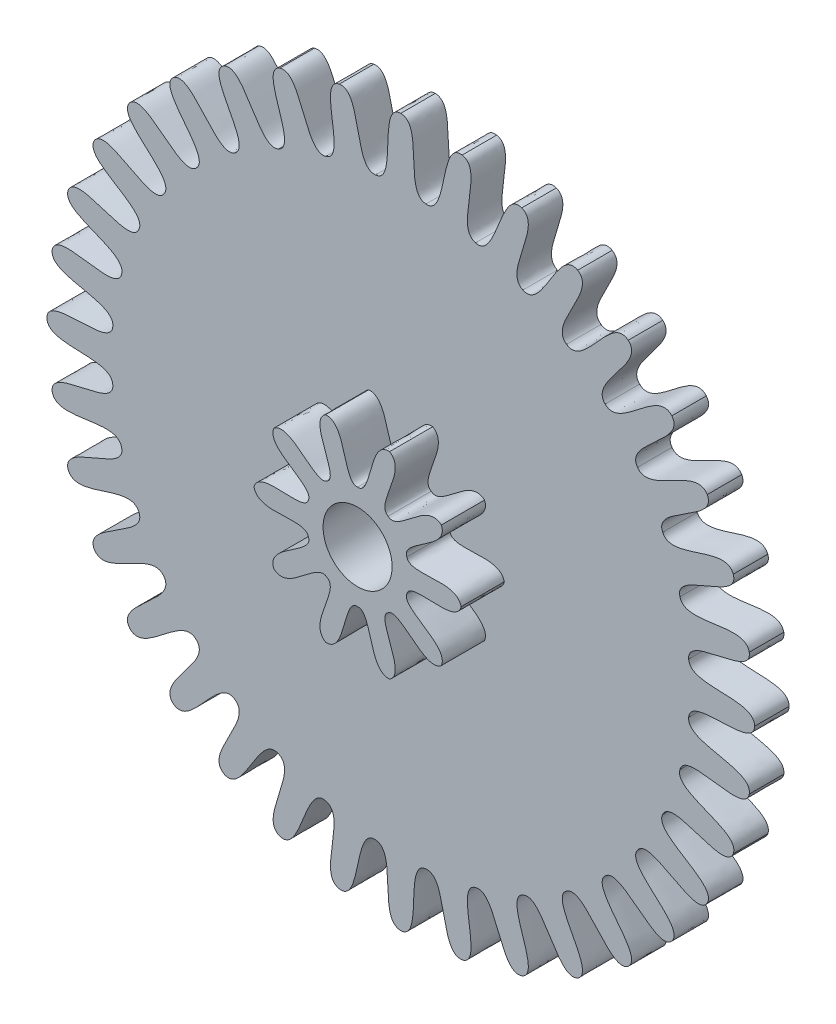
from build123d import *

# Parameters (mm, degrees)
BOSS_EXTRUDE1_36_TEETH_DEPTH = 0.4
BOSS_EXTRUDE2_10_TEETH_DEPTH = 0.5
SKETCH3_R                    = 0.4
CUT_EXTRUDE1_DEPTH           = 1.9000001


with BuildPart() as part:
    # Sketch1 → Boss-Extrude1 (36 teeth) (new body)
    with BuildSketch(Plane.XY):
        with BuildLine():
            add(Edge.make_bspline(
                [(0, 4.1), (0.270247794, 4.09375239), (0.032008591, 3.35367331), (0.291880112, 3.336204946)],
                knots=[0, 0, 0, 0, 1, 1, 1, 1], degree=3))
            add(Edge.make_bspline(
                [(0.711957528, 4.037711787), (0.44473052, 4.07848713), (0.55083695, 3.308281711), (0.291880112, 3.336204946)],
                knots=[0, 0, 0, 0, 1, 1, 1, 1], degree=3))
            add(Edge.make_bspline(
                [(0.711957528, 4.037711787), (0.977014765, 3.984631056), (0.613881568, 3.297165243), (0.866771706, 3.234836047)],
                knots=[0, 0, 0, 0, 1, 1, 1, 1], degree=3))
            add(Edge.make_bspline(
                [(1.402282588, 3.852739745), (1.146195922, 3.939299101), (1.116945589, 3.162369645), (0.866771706, 3.234836047)],
                knots=[0, 0, 0, 0, 1, 1, 1, 1], degree=3))
            add(Edge.make_bspline(
                [(1.402282588, 3.852739745), (1.654095637, 3.754438723), (1.177102063, 3.140474479), (1.415326881, 3.035178291)],
                knots=[0, 0, 0, 0, 1, 1, 1, 1], degree=3))
            add(Edge.make_bspline(
                [(2.05, 3.550704156), (1.81283474, 3.680417463), (1.649116402, 2.920370578), (1.415326881, 3.035178291)],
                knots=[0, 0, 0, 0, 1, 1, 1, 1], degree=3))
            add(Edge.make_bspline(
                [(2.05, 3.550704156), (2.28091765, 3.41016967), (1.704556908, 2.888361987), (1.920878065, 2.743298179)],
                knots=[0, 0, 0, 0, 1, 1, 1, 1], degree=3))
            add(Edge.make_bspline(
                [(2.6354292, 3.140782217), (2.424391493, 3.309708203), (2.131179647, 2.589637529), (1.920878065, 2.743298179)],
                knots=[0, 0, 0, 0, 1, 1, 1, 1], degree=3))
            add(Edge.make_bspline(
                [(2.6354292, 3.140782217), (2.838435134, 2.962284337), (2.180219654, 2.548488078), (2.36806434, 2.36806434)],
                knots=[0, 0, 0, 0, 1, 1, 1, 1], degree=3))
            add(Edge.make_bspline(
                [(3.140782217, 2.6354292), (2.962284337, 2.838435134), (2.548488078, 2.180219654), (2.36806434, 2.36806434)],
                knots=[0, 0, 0, 0, 1, 1, 1, 1], degree=3))
            add(Edge.make_bspline(
                [(3.140782217, 2.6354292), (3.309708203, 2.424391493), (2.589637529, 2.131179647), (2.743298179, 1.920878065)],
                knots=[0, 0, 0, 0, 1, 1, 1, 1], degree=3))
            add(Edge.make_bspline(
                [(3.550704156, 2.05), (3.41016967, 2.28091765), (2.888361987, 1.704556908), (2.743298179, 1.920878065)],
                knots=[0, 0, 0, 0, 1, 1, 1, 1], degree=3))
            add(Edge.make_bspline(
                [(3.550704156, 2.05), (3.680417463, 1.81283474), (2.920370578, 1.649116402), (3.035178291, 1.415326881)],
                knots=[0, 0, 0, 0, 1, 1, 1, 1], degree=3))
            add(Edge.make_bspline(
                [(3.852739745, 1.402282588), (3.754438723, 1.654095637), (3.140474479, 1.177102063), (3.035178291, 1.415326881)],
                knots=[0, 0, 0, 0, 1, 1, 1, 1], degree=3))
            add(Edge.make_bspline(
                [(3.852739745, 1.402282588), (3.939299101, 1.146195922), (3.162369645, 1.116945589), (3.234836047, 0.866771706)],
                knots=[0, 0, 0, 0, 1, 1, 1, 1], degree=3))
            add(Edge.make_bspline(
                [(4.037711787, 0.711957528), (3.984631056, 0.977014765), (3.297165243, 0.613881568), (3.234836047, 0.866771706)],
                knots=[0, 0, 0, 0, 1, 1, 1, 1], degree=3))
            add(Edge.make_bspline(
                [(4.037711787, 0.711957528), (4.07848713, 0.44473052), (3.308281711, 0.55083695), (3.336204946, 0.291880112)],
                knots=[0, 0, 0, 0, 1, 1, 1, 1], degree=3))
            add(Edge.make_bspline(
                [(4.1, 0), (4.09375239, 0.270247794), (3.35367331, 0.032008591), (3.336204946, 0.291880112)],
                knots=[0, 0, 0, 0, 1, 1, 1, 1], degree=3))
            add(Edge.make_bspline(
                [(4.1, 0), (4.09375239, -0.270247794), (3.35367331, -0.032008591), (3.336204946, -0.291880112)],
                knots=[0, 0, 0, 0, 1, 1, 1, 1], degree=3))
            add(Edge.make_bspline(
                [(4.037711787, -0.711957528), (4.07848713, -0.44473052), (3.308281711, -0.55083695), (3.336204946, -0.291880112)],
                knots=[0, 0, 0, 0, 1, 1, 1, 1], degree=3))
            add(Edge.make_bspline(
                [(4.037711787, -0.711957528), (3.984631056, -0.977014765), (3.297165243, -0.613881568), (3.234836047, -0.866771706)],
                knots=[0, 0, 0, 0, 1, 1, 1, 1], degree=3))
            add(Edge.make_bspline(
                [(3.852739745, -1.402282588), (3.939299101, -1.146195922), (3.162369645, -1.116945589), (3.234836047, -0.866771706)],
                knots=[0, 0, 0, 0, 1, 1, 1, 1], degree=3))
            add(Edge.make_bspline(
                [(3.852739745, -1.402282588), (3.754438723, -1.654095637), (3.140474479, -1.177102063), (3.035178291, -1.415326881)],
                knots=[0, 0, 0, 0, 1, 1, 1, 1], degree=3))
            add(Edge.make_bspline(
                [(3.550704156, -2.05), (3.680417463, -1.81283474), (2.920370578, -1.649116402), (3.035178291, -1.415326881)],
                knots=[0, 0, 0, 0, 1, 1, 1, 1], degree=3))
            add(Edge.make_bspline(
                [(3.550704156, -2.05), (3.41016967, -2.28091765), (2.888361987, -1.704556908), (2.743298179, -1.920878065)],
                knots=[0, 0, 0, 0, 1, 1, 1, 1], degree=3))
            add(Edge.make_bspline(
                [(3.140782217, -2.6354292), (3.309708203, -2.424391493), (2.589637529, -2.131179647), (2.743298179, -1.920878065)],
                knots=[0, 0, 0, 0, 1, 1, 1, 1], degree=3))
            add(Edge.make_bspline(
                [(3.140782217, -2.6354292), (2.962284337, -2.838435134), (2.548488078, -2.180219654), (2.36806434, -2.36806434)],
                knots=[0, 0, 0, 0, 1, 1, 1, 1], degree=3))
            add(Edge.make_bspline(
                [(2.6354292, -3.140782217), (2.838435134, -2.962284337), (2.180219654, -2.548488078), (2.36806434, -2.36806434)],
                knots=[0, 0, 0, 0, 1, 1, 1, 1], degree=3))
            add(Edge.make_bspline(
                [(2.6354292, -3.140782217), (2.424391493, -3.309708203), (2.131179647, -2.589637529), (1.920878065, -2.743298179)],
                knots=[0, 0, 0, 0, 1, 1, 1, 1], degree=3))
            add(Edge.make_bspline(
                [(2.05, -3.550704156), (2.28091765, -3.41016967), (1.704556908, -2.888361987), (1.920878065, -2.743298179)],
                knots=[0, 0, 0, 0, 1, 1, 1, 1], degree=3))
            add(Edge.make_bspline(
                [(2.05, -3.550704156), (1.81283474, -3.680417463), (1.649116402, -2.920370578), (1.415326881, -3.035178291)],
                knots=[0, 0, 0, 0, 1, 1, 1, 1], degree=3))
            add(Edge.make_bspline(
                [(1.402282588, -3.852739745), (1.654095637, -3.754438723), (1.177102063, -3.140474479), (1.415326881, -3.035178291)],
                knots=[0, 0, 0, 0, 1, 1, 1, 1], degree=3))
            add(Edge.make_bspline(
                [(1.402282588, -3.852739745), (1.146195922, -3.939299101), (1.116945589, -3.162369645), (0.866771706, -3.234836047)],
                knots=[0, 0, 0, 0, 1, 1, 1, 1], degree=3))
            add(Edge.make_bspline(
                [(0.711957528, -4.037711787), (0.977014765, -3.984631056), (0.613881568, -3.297165243), (0.866771706, -3.234836047)],
                knots=[0, 0, 0, 0, 1, 1, 1, 1], degree=3))
            add(Edge.make_bspline(
                [(0.711957528, -4.037711787), (0.44473052, -4.07848713), (0.55083695, -3.308281711), (0.291880112, -3.336204946)],
                knots=[0, 0, 0, 0, 1, 1, 1, 1], degree=3))
            add(Edge.make_bspline(
                [(0, -4.1), (0.270247794, -4.09375239), (0.032008591, -3.35367331), (0.291880112, -3.336204946)],
                knots=[0, 0, 0, 0, 1, 1, 1, 1], degree=3))
            add(Edge.make_bspline(
                [(0, -4.1), (-0.270247794, -4.09375239), (-0.032008591, -3.35367331), (-0.291880112, -3.336204946)],
                knots=[0, 0, 0, 0, 1, 1, 1, 1], degree=3))
            add(Edge.make_bspline(
                [(-0.711957528, -4.037711787), (-0.44473052, -4.07848713), (-0.55083695, -3.308281711), (-0.291880112, -3.336204946)],
                knots=[0, 0, 0, 0, 1, 1, 1, 1], degree=3))
            add(Edge.make_bspline(
                [(-0.711957528, -4.037711787), (-0.977014765, -3.984631056), (-0.613881568, -3.297165243), (-0.866771706, -3.234836047)],
                knots=[0, 0, 0, 0, 1, 1, 1, 1], degree=3))
            add(Edge.make_bspline(
                [(-1.402282588, -3.852739745), (-1.146195922, -3.939299101), (-1.116945589, -3.162369645), (-0.866771706, -3.234836047)],
                knots=[0, 0, 0, 0, 1, 1, 1, 1], degree=3))
            add(Edge.make_bspline(
                [(-1.402282588, -3.852739745), (-1.654095637, -3.754438723), (-1.177102063, -3.140474479), (-1.415326881, -3.035178291)],
                knots=[0, 0, 0, 0, 1, 1, 1, 1], degree=3))
            add(Edge.make_bspline(
                [(-2.05, -3.550704156), (-1.81283474, -3.680417463), (-1.649116402, -2.920370578), (-1.415326881, -3.035178291)],
                knots=[0, 0, 0, 0, 1, 1, 1, 1], degree=3))
            add(Edge.make_bspline(
                [(-2.05, -3.550704156), (-2.28091765, -3.41016967), (-1.704556908, -2.888361987), (-1.920878065, -2.743298179)],
                knots=[0, 0, 0, 0, 1, 1, 1, 1], degree=3))
            add(Edge.make_bspline(
                [(-2.6354292, -3.140782217), (-2.424391493, -3.309708203), (-2.131179647, -2.589637529), (-1.920878065, -2.743298179)],
                knots=[0, 0, 0, 0, 1, 1, 1, 1], degree=3))
            add(Edge.make_bspline(
                [(-2.6354292, -3.140782217), (-2.838435134, -2.962284337), (-2.180219654, -2.548488078), (-2.36806434, -2.36806434)],
                knots=[0, 0, 0, 0, 1, 1, 1, 1], degree=3))
            add(Edge.make_bspline(
                [(-3.140782217, -2.6354292), (-2.962284337, -2.838435134), (-2.548488078, -2.180219654), (-2.36806434, -2.36806434)],
                knots=[0, 0, 0, 0, 1, 1, 1, 1], degree=3))
            add(Edge.make_bspline(
                [(-3.140782217, -2.6354292), (-3.309708203, -2.424391493), (-2.589637529, -2.131179647), (-2.743298179, -1.920878065)],
                knots=[0, 0, 0, 0, 1, 1, 1, 1], degree=3))
            add(Edge.make_bspline(
                [(-3.550704156, -2.05), (-3.41016967, -2.28091765), (-2.888361987, -1.704556908), (-2.743298179, -1.920878065)],
                knots=[0, 0, 0, 0, 1, 1, 1, 1], degree=3))
            add(Edge.make_bspline(
                [(-3.550704156, -2.05), (-3.680417463, -1.81283474), (-2.920370578, -1.649116402), (-3.035178291, -1.415326881)],
                knots=[0, 0, 0, 0, 1, 1, 1, 1], degree=3))
            add(Edge.make_bspline(
                [(-3.852739745, -1.402282588), (-3.754438723, -1.654095637), (-3.140474479, -1.177102063), (-3.035178291, -1.415326881)],
                knots=[0, 0, 0, 0, 1, 1, 1, 1], degree=3))
            add(Edge.make_bspline(
                [(-3.852739745, -1.402282588), (-3.939299101, -1.146195922), (-3.162369645, -1.116945589), (-3.234836047, -0.866771706)],
                knots=[0, 0, 0, 0, 1, 1, 1, 1], degree=3))
            add(Edge.make_bspline(
                [(-4.037711787, -0.711957528), (-3.984631056, -0.977014765), (-3.297165243, -0.613881568), (-3.234836047, -0.866771706)],
                knots=[0, 0, 0, 0, 1, 1, 1, 1], degree=3))
            add(Edge.make_bspline(
                [(-4.037711787, -0.711957528), (-4.07848713, -0.44473052), (-3.308281711, -0.55083695), (-3.336204946, -0.291880112)],
                knots=[0, 0, 0, 0, 1, 1, 1, 1], degree=3))
            add(Edge.make_bspline(
                [(-4.1, 0), (-4.09375239, -0.270247794), (-3.35367331, -0.032008591), (-3.336204946, -0.291880112)],
                knots=[0, 0, 0, 0, 1, 1, 1, 1], degree=3))
            add(Edge.make_bspline(
                [(-4.1, 0), (-4.09375239, 0.270247794), (-3.35367331, 0.032008591), (-3.336204946, 0.291880112)],
                knots=[0, 0, 0, 0, 1, 1, 1, 1], degree=3))
            add(Edge.make_bspline(
                [(-4.037711787, 0.711957528), (-4.07848713, 0.44473052), (-3.308281711, 0.55083695), (-3.336204946, 0.291880112)],
                knots=[0, 0, 0, 0, 1, 1, 1, 1], degree=3))
            add(Edge.make_bspline(
                [(-4.037711787, 0.711957528), (-3.984631056, 0.977014765), (-3.297165243, 0.613881568), (-3.234836047, 0.866771706)],
                knots=[0, 0, 0, 0, 1, 1, 1, 1], degree=3))
            add(Edge.make_bspline(
                [(-3.852739745, 1.402282588), (-3.939299101, 1.146195922), (-3.162369645, 1.116945589), (-3.234836047, 0.866771706)],
                knots=[0, 0, 0, 0, 1, 1, 1, 1], degree=3))
            add(Edge.make_bspline(
                [(-3.852739745, 1.402282588), (-3.754438723, 1.654095637), (-3.140474479, 1.177102063), (-3.035178291, 1.415326881)],
                knots=[0, 0, 0, 0, 1, 1, 1, 1], degree=3))
            add(Edge.make_bspline(
                [(-3.550704156, 2.05), (-3.680417463, 1.81283474), (-2.920370578, 1.649116402), (-3.035178291, 1.415326881)],
                knots=[0, 0, 0, 0, 1, 1, 1, 1], degree=3))
            add(Edge.make_bspline(
                [(-3.550704156, 2.05), (-3.41016967, 2.28091765), (-2.888361987, 1.704556908), (-2.743298179, 1.920878065)],
                knots=[0, 0, 0, 0, 1, 1, 1, 1], degree=3))
            add(Edge.make_bspline(
                [(-3.140782217, 2.6354292), (-3.309708203, 2.424391493), (-2.589637529, 2.131179647), (-2.743298179, 1.920878065)],
                knots=[0, 0, 0, 0, 1, 1, 1, 1], degree=3))
            add(Edge.make_bspline(
                [(-3.140782217, 2.6354292), (-2.962284337, 2.838435134), (-2.548488078, 2.180219654), (-2.36806434, 2.36806434)],
                knots=[0, 0, 0, 0, 1, 1, 1, 1], degree=3))
            add(Edge.make_bspline(
                [(-2.6354292, 3.140782217), (-2.838435134, 2.962284337), (-2.180219654, 2.548488078), (-2.36806434, 2.36806434)],
                knots=[0, 0, 0, 0, 1, 1, 1, 1], degree=3))
            add(Edge.make_bspline(
                [(-2.6354292, 3.140782217), (-2.424391493, 3.309708203), (-2.131179647, 2.589637529), (-1.920878065, 2.743298179)],
                knots=[0, 0, 0, 0, 1, 1, 1, 1], degree=3))
            add(Edge.make_bspline(
                [(-2.05, 3.550704156), (-2.28091765, 3.41016967), (-1.704556908, 2.888361987), (-1.920878065, 2.743298179)],
                knots=[0, 0, 0, 0, 1, 1, 1, 1], degree=3))
            add(Edge.make_bspline(
                [(-2.05, 3.550704156), (-1.81283474, 3.680417463), (-1.649116402, 2.920370578), (-1.415326881, 3.035178291)],
                knots=[0, 0, 0, 0, 1, 1, 1, 1], degree=3))
            add(Edge.make_bspline(
                [(-1.402282588, 3.852739745), (-1.654095637, 3.754438723), (-1.177102063, 3.140474479), (-1.415326881, 3.035178291)],
                knots=[0, 0, 0, 0, 1, 1, 1, 1], degree=3))
            add(Edge.make_bspline(
                [(-1.402282588, 3.852739745), (-1.146195922, 3.939299101), (-1.116945589, 3.162369645), (-0.866771706, 3.234836047)],
                knots=[0, 0, 0, 0, 1, 1, 1, 1], degree=3))
            add(Edge.make_bspline(
                [(-0.711957528, 4.037711787), (-0.977014765, 3.984631056), (-0.613881568, 3.297165243), (-0.866771706, 3.234836047)],
                knots=[0, 0, 0, 0, 1, 1, 1, 1], degree=3))
            add(Edge.make_bspline(
                [(-0.711957528, 4.037711787), (-0.44473052, 4.07848713), (-0.55083695, 3.308281711), (-0.291880112, 3.336204946)],
                knots=[0, 0, 0, 0, 1, 1, 1, 1], degree=3))
            add(Edge.make_bspline(
                [(0, 4.1), (-0.270247794, 4.09375239), (-0.032008591, 3.35367331), (-0.291880112, 3.336204946)],
                knots=[0, 0, 0, 0, 1, 1, 1, 1], degree=3))
        make_face()
    extrude(amount=BOSS_EXTRUDE1_36_TEETH_DEPTH)

    # Sketch2 → Boss-Extrude2 (10 teeth) (add)
    with BuildSketch(Plane.XY.offset(0.4)):
        with BuildLine():
            add(Edge.make_bspline(
                [(0.370820393, 1.14126782), (0.5807229, 1.012849813), (0.202117272, 0.569471295), (0.352671151, 0.485410197)],
                knots=[0, 0, 0, 0, 1, 1, 1, 1], degree=3))
            add(Edge.make_bspline(
                [(0.970820393, 0.705342303), (0.78382417, 0.865288103), (0.479141714, 0.368201257), (0.352671151, 0.485410197)],
                knots=[0, 0, 0, 0, 1, 1, 1, 1], degree=3))
            add(Edge.make_bspline(
                [(0.970820393, 0.705342303), (1.065152878, 0.478072355), (0.498243137, 0.341910404), (0.57063391, 0.185410197)],
                knots=[0, 0, 0, 0, 1, 1, 1, 1], degree=3))
            add(Edge.make_bspline(
                [(1.2, 0), (1.14273066, 0.239312493), (0.604057058, 0.016248641), (0.57063391, 0.185410197)],
                knots=[0, 0, 0, 0, 1, 1, 1, 1], degree=3))
            add(Edge.make_bspline(
                [(1.2, 0), (1.14273066, -0.239312493), (0.604057058, -0.016248641), (0.57063391, -0.185410197)],
                knots=[0, 0, 0, 0, 1, 1, 1, 1], degree=3))
            add(Edge.make_bspline(
                [(0.970820393, -0.705342303), (1.065152878, -0.478072355), (0.498243137, -0.341910404), (0.57063391, -0.185410197)],
                knots=[0, 0, 0, 0, 1, 1, 1, 1], degree=3))
            add(Edge.make_bspline(
                [(0.970820393, -0.705342303), (0.78382417, -0.865288103), (0.479141714, -0.368201257), (0.352671151, -0.485410197)],
                knots=[0, 0, 0, 0, 1, 1, 1, 1], degree=3))
            add(Edge.make_bspline(
                [(0.370820393, -1.14126782), (0.5807229, -1.012849813), (0.202117272, -0.569471295), (0.352671151, -0.485410197)],
                knots=[0, 0, 0, 0, 1, 1, 1, 1], degree=3))
            add(Edge.make_bspline(
                [(0.370820393, -1.14126782), (0.125523488, -1.160753068), (0.171210521, -0.579513507), (0, -0.6)],
                knots=[0, 0, 0, 0, 1, 1, 1, 1], degree=3))
            add(Edge.make_bspline(
                [(-0.370820393, -1.14126782), (-0.125523488, -1.160753068), (-0.171210521, -0.579513507), (0, -0.6)],
                knots=[0, 0, 0, 0, 1, 1, 1, 1], degree=3))
            add(Edge.make_bspline(
                [(-0.370820393, -1.14126782), (-0.5807229, -1.012849813), (-0.202117272, -0.569471295), (-0.352671151, -0.485410197)],
                knots=[0, 0, 0, 0, 1, 1, 1, 1], degree=3))
            add(Edge.make_bspline(
                [(-0.970820393, -0.705342303), (-0.78382417, -0.865288103), (-0.479141714, -0.368201257), (-0.352671151, -0.485410197)],
                knots=[0, 0, 0, 0, 1, 1, 1, 1], degree=3))
            add(Edge.make_bspline(
                [(-0.970820393, -0.705342303), (-1.065152878, -0.478072355), (-0.498243137, -0.341910404), (-0.57063391, -0.185410197)],
                knots=[0, 0, 0, 0, 1, 1, 1, 1], degree=3))
            add(Edge.make_bspline(
                [(-1.2, 0), (-1.14273066, -0.239312493), (-0.604057058, -0.016248641), (-0.57063391, -0.185410197)],
                knots=[0, 0, 0, 0, 1, 1, 1, 1], degree=3))
            add(Edge.make_bspline(
                [(-1.2, 0), (-1.14273066, 0.239312493), (-0.604057058, 0.016248641), (-0.57063391, 0.185410197)],
                knots=[0, 0, 0, 0, 1, 1, 1, 1], degree=3))
            add(Edge.make_bspline(
                [(-0.970820393, 0.705342303), (-1.065152878, 0.478072355), (-0.498243137, 0.341910404), (-0.57063391, 0.185410197)],
                knots=[0, 0, 0, 0, 1, 1, 1, 1], degree=3))
            add(Edge.make_bspline(
                [(-0.970820393, 0.705342303), (-0.78382417, 0.865288103), (-0.479141714, 0.368201257), (-0.352671151, 0.485410197)],
                knots=[0, 0, 0, 0, 1, 1, 1, 1], degree=3))
            add(Edge.make_bspline(
                [(-0.370820393, 1.14126782), (-0.5807229, 1.012849813), (-0.202117272, 0.569471295), (-0.352671151, 0.485410197)],
                knots=[0, 0, 0, 0, 1, 1, 1, 1], degree=3))
            add(Edge.make_bspline(
                [(-0.370820393, 1.14126782), (-0.125523488, 1.160753068), (-0.171210521, 0.579513507), (0, 0.6)],
                knots=[0, 0, 0, 0, 1, 1, 1, 1], degree=3))
            add(Edge.make_bspline(
                [(0.370820393, 1.14126782), (0.125523488, 1.160753068), (0.171210521, 0.579513507), (0, 0.6)],
                knots=[0, 0, 0, 0, 1, 1, 1, 1], degree=3))
        make_face()
    extrude(amount=BOSS_EXTRUDE2_10_TEETH_DEPTH)

    # Sketch3 → Cut-Extrude1 (cut, through all)
    with BuildSketch(Plane.XY):
        Circle(SKETCH3_R)
    extrude(amount=CUT_EXTRUDE1_DEPTH, mode=Mode.SUBTRACT)


solid = part.part
